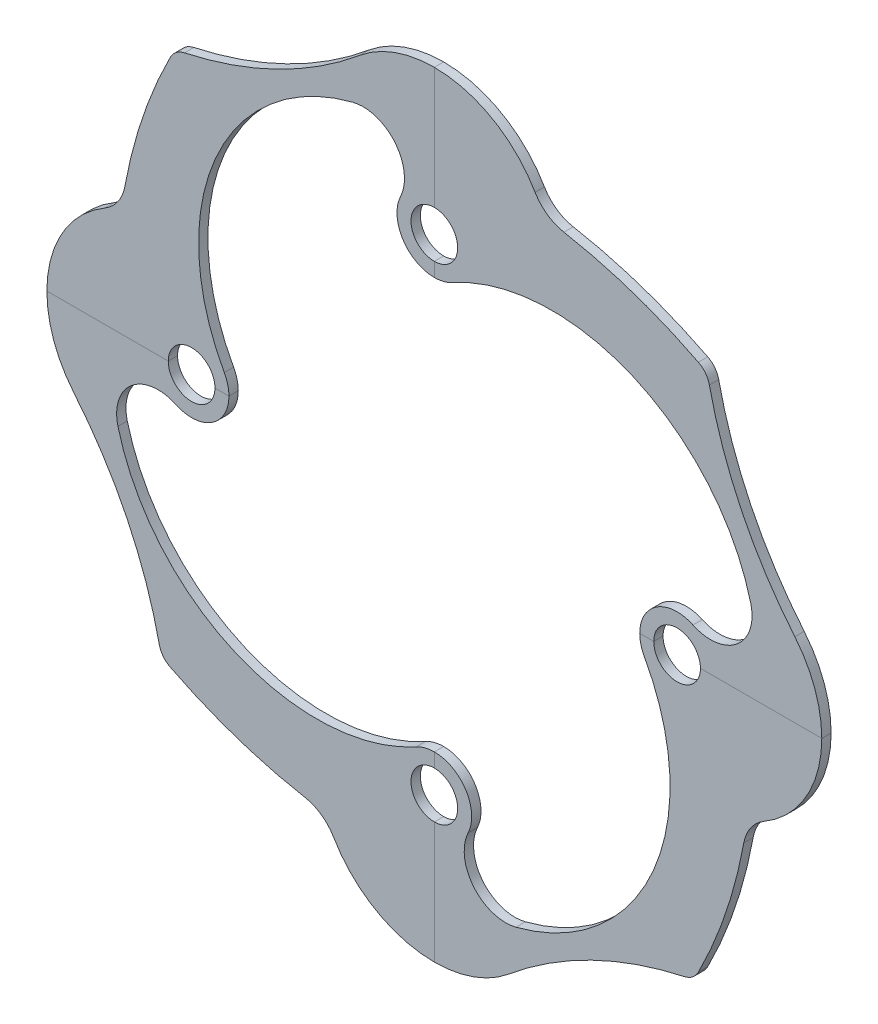
from build123d import *

# Parameters (mm, degrees)
LINEAR_AUSTRAGEN1_DEPTH = 1
KREISMUSTER1_COUNT      = 4


with BuildPart() as part:
    # Au_enkontur → Linear austragen1 (new body, symmetric)
    with BuildSketch(Plane.XY):
        with BuildLine():
            Line((-83, 0), (-57, 0))
            ThreePointArc((-57, 0), (-52, 5), (-47, 0))
            Line((-47, 0), (-44, 0))
            ThreePointArc((-44, 0), (-44.254033308, 2), (-45, 3.872983346))
            ThreePointArc((-45, 3.872983346), (-46.916580756, 42.566918881), (-17.5, 67.777208559))
            ThreePointArc((-17.5, 67.777208559), (-8.441984355, 64.845892989), (-7.240867658, 55.401446097))
            ThreePointArc((-7.240867658, 55.401446097), (-6.75320549, 47.711152181), (0, 44))
            Line((0, 44), (0, 47))
            ThreePointArc((0, 47), (-5, 52), (0, 57))
            Line((0, 57), (0, 83))
            ThreePointArc((0, 83), (-8.493750568, 81.512894362), (-15.977012787, 77.228496103))
            ThreePointArc((-15.977012787, 77.228496103), (-33.644463337, 65.816474944), (-53.515303741, 58.922801215))
            ThreePointArc((-53.515303741, 58.922801215), (-55.306825995, 58.089224466), (-56.568542495, 56.568542495))
            ThreePointArc((-56.568542495, 56.568542495), (-62.483030705, 42.514608), (-66.293095094, 27.75054166))
            ThreePointArc((-66.293095094, 27.75054166), (-67.776085308, 24.196284331), (-70.608999234, 21.587337453))
            ThreePointArc((-70.608999234, 21.587337453), (-79.682077632, 12.445381054), (-83, 0))
        make_face()
    extrude(amount=LINEAR_AUSTRAGEN1_DEPTH, both=True)


with BuildPart() as kreismuster1_1:
    # Kreismuster1: pattern copy
    add(part.part.rotate(Axis((0, 0, 0), (0, 0, 1)), 1 * 360 / KREISMUSTER1_COUNT))


with BuildPart() as kreismuster1_2:
    # Kreismuster1: pattern copy
    add(part.part.rotate(Axis((0, 0, 0), (0, 0, 1)), 2 * 360 / KREISMUSTER1_COUNT))


with BuildPart() as kreismuster1_3:
    # Kreismuster1: pattern copy
    add(part.part.rotate(Axis((0, 0, 0), (0, 0, 1)), 3 * 360 / KREISMUSTER1_COUNT))


solid = Compound([part.part, kreismuster1_1.part, kreismuster1_2.part, kreismuster1_3.part])
